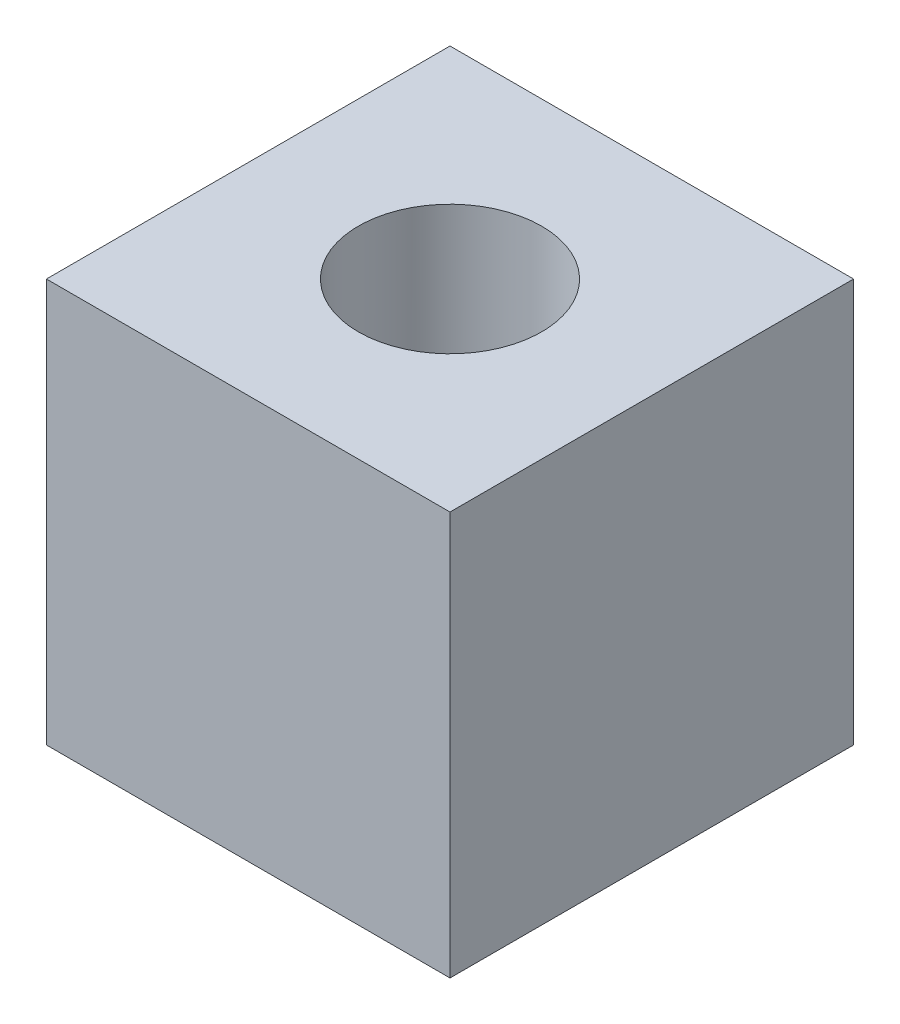
from build123d import *

# Parameters (mm, degrees)
SKETCH1_W           = 12
SKETCH1_H           = 12
SKETCH1_R           = 2.725
BOSS_EXTRUDE1_DEPTH = 12
SKETCH2_R           = 2.725
SKETCH2_R_2         = 2.25
BOSS_EXTRUDE2_DEPTH = 4


with BuildPart() as part:
    # Sketch1 → Boss-Extrude1 (new body)
    with BuildSketch(Plane(origin=(0, 0, 0), x_dir=(1, 0, 0), z_dir=(0, 1, 0))):
        Rectangle(SKETCH1_W, SKETCH1_H)
        Circle(SKETCH1_R, mode=Mode.SUBTRACT)
    extrude(amount=BOSS_EXTRUDE1_DEPTH)

    # Sketch2 → Boss-Extrude2 (add)
    with BuildSketch(Plane.XZ):
        Circle(SKETCH2_R)
        Circle(SKETCH2_R_2, mode=Mode.SUBTRACT)
    extrude(amount=-BOSS_EXTRUDE2_DEPTH)


solid = part.part
